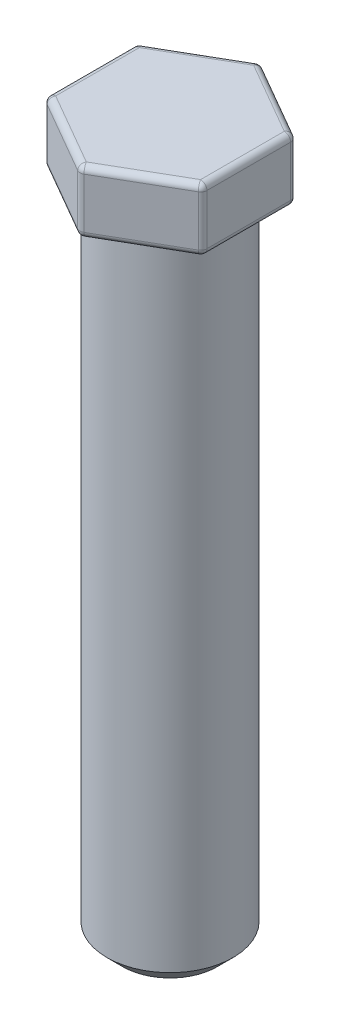
from build123d import *

# Parameters (mm, degrees)
SKETCH1_R           = 2
BOSS_EXTRUDE1_DEPTH = 20.7
BOSS_EXTRUDE2_DEPTH = 2
CHAMFER1_SIZE       = 0.5
FILLET1_R           = 0.2


with BuildPart() as part:
    # Sketch1 → Boss-Extrude1 (new body)
    with BuildSketch(Plane(origin=(0, 0, 0), x_dir=(1, 0, 0), z_dir=(0, 1, 0))):
        Circle(SKETCH1_R)
    extrude(amount=BOSS_EXTRUDE1_DEPTH)

    # Sketch2 → Boss-Extrude2 (add)
    with BuildSketch(Plane(origin=(0, 20.7, 0), x_dir=(1, 0, 0), z_dir=(0, 1, 0))):
        Polygon((2.5, -1.443375673), (2.5, 1.443375673), (0, 2.886751346), (-2.5, 1.443375673), (-2.5, -1.443375673), (0, -2.886751346), align=None)
    extrude(amount=BOSS_EXTRUDE2_DEPTH)

    # Chamfer1
    chamfer1_edges = [part.edges().sort_by_distance(p)[0] for p in [
        (-2, 0, 0),
    ]]
    chamfer(chamfer1_edges, length=CHAMFER1_SIZE)

    # Fillet1
    fillet1_edges = [part.edges().sort_by_distance(p)[0] for p in [
        (-2, 20.7, 0),
        (1.25, 20.7, 2.165063509),
        (0, 21.7, 2.886751346),
        (2.5, 20.7, 0),
        (2.5, 21.7, 1.443375673),
        (1.25, 20.7, -2.165063509),
        (2.5, 21.7, -1.443375673),
        (-1.25, 20.7, -2.165063509),
        (0, 21.7, -2.886751346),
        (-2.5, 20.7, 0),
        (-2.5, 21.7, -1.443375673),
        (-1.25, 20.7, 2.165063509),
        (-2.5, 21.7, 1.443375673),
        (1.25, 22.7, 2.165063509),
        (2.5, 22.7, 0),
        (1.25, 22.7, -2.165063509),
        (-1.25, 22.7, -2.165063509),
        (-2.5, 22.7, 0),
        (-1.25, 22.7, 2.165063509),
    ]]
    fillet(fillet1_edges, radius=FILLET1_R)


solid = part.part
